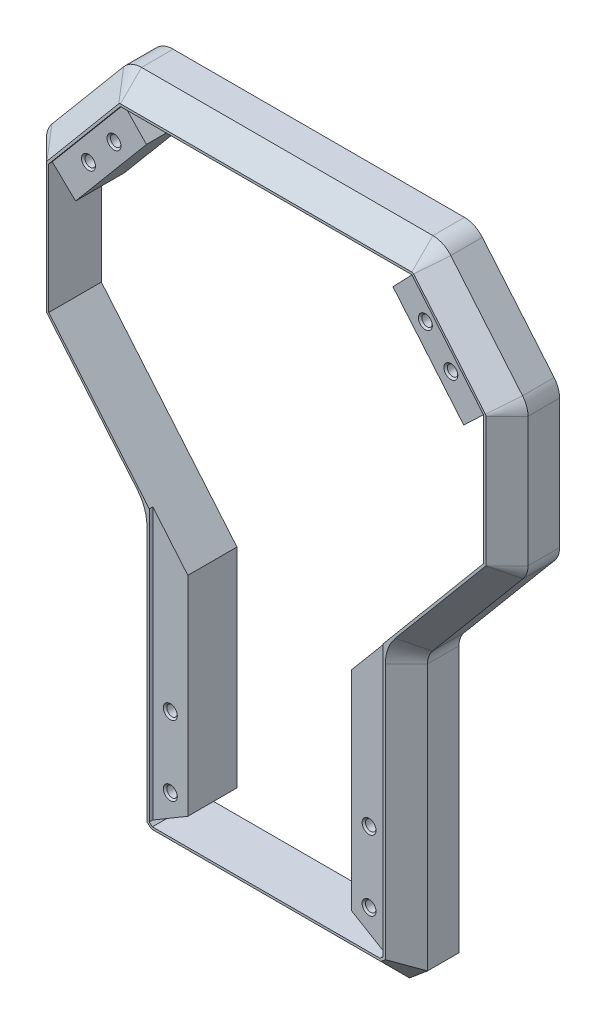
from build123d import *

# Parameters (mm, degrees)
RESSALTO_EXTRUS_O1_DEPTH                            = 22.5
CHANFRO1_SIZE                                       = 9
CORTE_EXTRUS_O1_REACH                               = 24.5
ESBO_O3_W                                           = 1139.230904301
ESBO_O3_H                                           = 709.798033895
CORTE_EXTRUS_O5_DEPTH                               = 1.5
CORTE_EXTRUS_O6_REACH                               = 23
ESCAREADO_PARA_PARAFUSO_ALLEN_SEXTAVADO_D           = 4.5
ESCAREADO_PARA_PARAFUSO_ALLEN_SEXTAVADO_CSINK_D     = 8.96
ESCAREADO_PARA_PARAFUSO_ALLEN_SEXTAVADO_CSINK_ANGLE = 90
CORTE_EXTRUS_O7_DEPTH                               = 10


with BuildPart() as part:
    # Esboço1 → Ressalto-extrusão1 (new body, symmetric)
    with BuildSketch(Plane.XY):
        with BuildLine():
            Line((-62.301435521, 279.499553668), (62.301435521, 279.499553668))
            ThreePointArc((62.301435521, 279.499553668), (66.527618138, 278.562631538), (69.961879952, 275.927429764))
            Line((69.961879952, 275.927429764), (100.660444431, 239.342305259))
            ThreePointArc((100.660444431, 239.342305259), (102.396926208, 236.334630596), (103, 232.914429162))
            Line((103, 232.914429162), (103, 177.526516487))
            ThreePointArc((103, 177.526516487), (102.453136861, 174.425101506), (100.878507208, 171.697762944))
            Line((100.878507208, 171.697762944), (62.121492792, 125.508951777))
            ThreePointArc((62.121492792, 125.508951777), (60.546863139, 122.781613215), (60, 119.680198234))
            Line((60, 119.680198234), (60, 5.944191717))
            Line((60, 5.944191717), (52.319579452, -0.500446332))
            Line((52.319579452, -0.500446332), (-52.319579452, -0.500446332))
            Line((-52.319579452, -0.500446332), (-60, 5.944191717))
            Line((-60, 5.944191717), (-60, 119.680198234))
            ThreePointArc((-60, 119.680198234), (-60.546863139, 122.781613215), (-62.121492792, 125.508951777))
            Line((-62.121492792, 125.508951777), (-100.878507208, 171.697762944))
            ThreePointArc((-100.878507208, 171.697762944), (-102.453136861, 174.425101506), (-103, 177.526516487))
            Line((-103, 177.526516487), (-103, 232.914429162))
            ThreePointArc((-103, 232.914429162), (-102.396926208, 236.334630596), (-100.660444431, 239.342305259))
            Line((-100.660444431, 239.342305259), (-69.961879952, 275.927429764))
            ThreePointArc((-69.961879952, 275.927429764), (-66.527618138, 278.562631538), (-62.301435521, 279.499553668))
        make_face()
        Polygon((-52.721623425, 259.499553668), (52.721623425, 259.499553668), (83, 223.415189606), (83, 181.505464287), (35, 124.301291842), (35, 19.499553668), (-35, 19.499553668), (-35, 124.301291842), (-83, 181.505464287), (-83, 223.415189606), align=None, mode=Mode.SUBTRACT)
    extrude(amount=RESSALTO_EXTRUS_O1_DEPTH, both=True)

    # Chanfro1
    chanfro1_edges = [part.edges().sort_by_distance(p)[0] for p in [
        (0, -0.500446332, 22.5),
        (56.159789726, 2.721872692, 22.5),
        (60, 62.812194975, 22.5),
        (60.546863139, 122.781613215, 22.5),
        (81.5, 148.603357361, 22.5),
        (102.453136861, 174.425101506, 22.5),
        (103, 205.220472825, 22.5),
        (102.396926208, 236.334630596, 22.5),
        (85.311162192, 257.634867512, 22.5),
        (66.527618138, 278.562631538, 22.5),
        (0, 279.499553668, 22.5),
        (-66.527618138, 278.562631538, 22.5),
        (-85.311162192, 257.634867512, 22.5),
        (-102.396926208, 236.334630596, 22.5),
        (-103, 205.220472825, 22.5),
        (-102.453136861, 174.425101506, 22.5),
        (-81.5, 148.603357361, 22.5),
        (-60.546863139, 122.781613215, 22.5),
        (-60, 62.812194975, 22.5),
        (-56.159789726, 2.721872692, 22.5),
    ]]
    chamfer(chanfro1_edges, length=CHANFRO1_SIZE)

    # Esboço3 → Corte-extrusão1 (cut, up to next)
    with BuildSketch(Plane.XY, mode=Mode.PRIVATE) as corte_extrus_o1_sk1:
        with Locations((-153.157436203, 152.53565808)):
            Rectangle(ESBO_O3_W, ESBO_O3_H)
    corte_extrus_o1_tool1 = extrude(corte_extrus_o1_sk1.sketch, amount=-CORTE_EXTRUS_O1_REACH, mode=Mode.PRIVATE) & part.part
    add(corte_extrus_o1_tool1.solids().sort_by_distance((-153.157436, 152.535658, 0))[0], mode=Mode.SUBTRACT)

    # Esboço4 → Corte-extrusão5 (cut)
    with BuildSketch(Plane.XY.offset(22.5)):
        Polygon((62.301435521, 269.499553668), (-62.301435521, 269.499553668), (-93, 232.914429162), (-93, 177.865761944), (-50, 126.620357463), (-50, 10.607268298), (-48.679877109, 9.499553668), (48.679877109, 9.499553668), (50, 10.607268298), (50, 126.620357463), (93, 177.865761944), (93, 232.914429162), align=None)
        Polygon((35, 19.499553668), (-35, 19.499553668), (-35, 124.301291842), (-83, 181.505464287), (-83, 223.415189606), (-52.721623425, 259.499553668), (52.721623425, 259.499553668), (83, 223.415189606), (83, 181.505464287), (35, 124.301291842), align=None, mode=Mode.SUBTRACT)
    extrude(amount=-CORTE_EXTRUS_O5_DEPTH, mode=Mode.SUBTRACT)

    # Esboço5 → Corte-extrusão6 (cut, up to next)
    with BuildSketch(Plane.XY.offset(21), mode=Mode.PRIVATE) as corte_extrus_o6_sk1:
        Polygon((-93, 232.914429162), (-83, 223.415189606), (-83, 181.505464287), (-35, 124.301291842), (-35, 108.744053574), (-93, 177.865761944), align=None)
    corte_extrus_o6_tool1 = extrude(corte_extrus_o6_sk1.sketch, amount=-CORTE_EXTRUS_O6_REACH, mode=Mode.PRIVATE) & part.part
    add(corte_extrus_o6_tool1.solids().sort_by_distance((-88.943881, 227.171171, 21))[0], mode=Mode.SUBTRACT)
    # Esboço5 → Corte-extrusão6 (cut, up to next)
    with BuildSketch(Plane.XY.offset(21), mode=Mode.PRIVATE) as corte_extrus_o6_sk2:
        Polygon((-52.721623425, 259.499553668), (-62.301435521, 269.499553668), (62.301435521, 269.499553668), (52.721623425, 259.499553668), align=None)
    corte_extrus_o6_tool2 = extrude(corte_extrus_o6_sk2.sketch, amount=-CORTE_EXTRUS_O6_REACH, mode=Mode.PRIVATE) & part.part
    add(corte_extrus_o6_tool2.solids().sort_by_distance((0, 264.638364, 21))[0], mode=Mode.SUBTRACT)
    # Esboço5 → Corte-extrusão6 (cut, up to next)
    with BuildSketch(Plane.XY.offset(21), mode=Mode.PRIVATE) as corte_extrus_o6_sk3:
        Polygon((-50, 10.607268298), (-35, 19.499553668), (35, 19.499553668), (50, 10.607268298), (48.679877109, 9.499553668), (-48.679877109, 9.499553668), align=None)
    corte_extrus_o6_tool3 = extrude(corte_extrus_o6_sk3.sketch, amount=-CORTE_EXTRUS_O6_REACH, mode=Mode.PRIVATE) & part.part
    add(corte_extrus_o6_tool3.solids().sort_by_distance((0, 14.193497, 21))[0], mode=Mode.SUBTRACT)
    # Esboço5 → Corte-extrusão6 (cut, up to next)
    with BuildSketch(Plane.XY.offset(21), mode=Mode.PRIVATE) as corte_extrus_o6_sk4:
        Polygon((35, 108.744053574), (93, 177.865761944), (93, 232.914429162), (83, 223.415189606), (83, 181.505464287), (35, 124.301291842), align=None)
    corte_extrus_o6_tool4 = extrude(corte_extrus_o6_sk4.sketch, amount=-CORTE_EXTRUS_O6_REACH, mode=Mode.PRIVATE) & part.part
    add(corte_extrus_o6_tool4.solids().sort_by_distance((62.950148, 144.185838, 21))[0], mode=Mode.SUBTRACT)

    # Escareado para parafuso Allen sextavado escareado de M41 (through all)
    with Locations(Plane(origin=(-66.589178595, 253.499553668, 22.5), x_dir=(1, 0, 0), z_dir=(0, 0, 1))):
        with Locations((0, 0), (-10.908295205, -13), (133.17835719, 0), (144.086652395, -13), (24.089178595, -199), (24.089178595, -229), (109.089178595, -229), (109.089178595, -199)):
            CounterSinkHole(ESCAREADO_PARA_PARAFUSO_ALLEN_SEXTAVADO_D / 2, ESCAREADO_PARA_PARAFUSO_ALLEN_SEXTAVADO_CSINK_D / 2, counter_sink_angle=ESCAREADO_PARA_PARAFUSO_ALLEN_SEXTAVADO_CSINK_ANGLE)

    # Esboço9 → Corte-extrusão7 (cut)
    with BuildSketch(Plane(origin=(0, 0, 0), x_dir=(-1, 0, 0), z_dir=(0, 0, -1))):
        Polygon((-66.589178595, 257.541005552), (-70.089178595, 255.52027961), (-70.089178595, 251.478827725), (-66.589178595, 249.458101783), (-63.089178595, 251.478827725), (-63.089178595, 255.52027961), align=None)
        Polygon((-77.4974738, 244.541005552), (-80.9974738, 242.52027961), (-80.9974738, 238.478827725), (-77.4974738, 236.458101783), (-73.9974738, 238.478827725), (-73.9974738, 242.52027961), align=None)
        Polygon((-42.5, 58.541005552), (-46, 56.52027961), (-46, 52.478827725), (-42.5, 50.458101783), (-39, 52.478827725), (-39, 56.52027961), align=None)
        Polygon((-42.5, 28.541005552), (-46, 26.52027961), (-46, 22.478827725), (-42.5, 20.458101783), (-39, 22.478827725), (-39, 26.52027961), align=None)
        Polygon((39, 26.52027961), (42.5, 28.541005552), (46, 26.52027961), (46, 22.478827725), (42.5, 20.458101783), (39, 22.478827725), align=None)
        Polygon((39, 56.52027961), (42.5, 58.541005552), (46, 56.52027961), (46, 52.478827725), (42.5, 50.458101783), (39, 52.478827725), align=None)
        Polygon((73.9974738, 242.52027961), (77.4974738, 244.541005552), (80.9974738, 242.52027961), (80.9974738, 238.478827725), (77.4974738, 236.458101783), (73.9974738, 238.478827725), align=None)
        Polygon((63.089178595, 255.52027961), (66.589178595, 257.541005552), (70.089178595, 255.52027961), (70.089178595, 251.478827725), (66.589178595, 249.458101783), (63.089178595, 251.478827725), align=None)
    extrude(amount=-CORTE_EXTRUS_O7_DEPTH, mode=Mode.SUBTRACT)


solid = part.part
